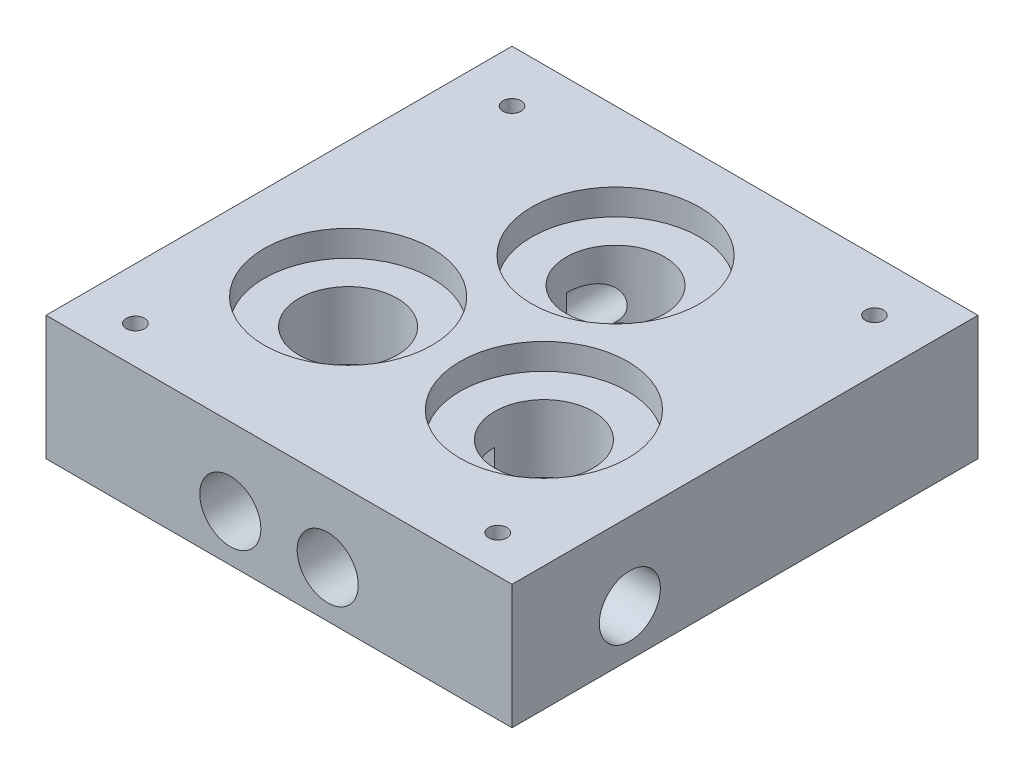
from build123d import *

# Parameters (mm, degrees)
SKETCH1_W                = 90.006
SKETCH1_H                = 90
SKETCH1_R                = 16.2
ALPHASENSE_HOUSING_DEPTH = 5
SKETCH2_W                = 90.006
SKETCH2_H                = 90
SKETCH2_R                = 9.5
CHAMBER_HOUSING_DEPTH    = 13
SKETCH3_W                = 90.006
SKETCH3_H                = 90
BASE_DEPTH               = 6
SKETCH5_R                = 5.9
DRILL_DEPTH              = 10
SKETCH6_R                = 5.9
DRILL2_DEPTH             = 10
SKETCH7_R                = 5.9
DRILL3_DEPTH             = 10
SKETCH8_R                = 5.9
INLETDRILL_DEPTH         = 10
SKETCH10_R               = 5.9
DRILL5_DEPTH             = 10
SKETCH11_R               = 5.9
OUTLEDRILL_DEPTH         = 10
SKETCH12_R               = 1.75
CLIPPINGTHREADS_DEPTH    = 10
SKETCH13_R               = 4
CUT_EXTRUDE1_DEPTH       = 35.003
SKETCH14_R               = 4
CUT_EXTRUDE2_DEPTH       = 16.098
SKETCH15_R               = 4
CUT_EXTRUDE3_DEPTH       = 22.255579
SKETCH16_R               = 4
CUT_EXTRUDE4_DEPTH       = 22.255579
SKETCH17_R               = 4
CUT_EXTRUDE5_DEPTH       = 16.098
SKETCH18_R               = 4
CUT_EXTRUDE6_DEPTH       = 15


with BuildPart() as part:
    # Sketch1 → Alphasense_housing (new body)
    with BuildSketch(Plane(origin=(0, 0, 0), x_dir=(1, 0, 0), z_dir=(0, 1, 0))):
        with Locations((0, 1.829613678)):
            Rectangle(SKETCH1_W, SKETCH1_H)
        with Locations((0, 21.829613678)):
            Circle(SKETCH1_R, mode=Mode.SUBTRACT)
        with Locations((-18.905, -10.914806839)):
            Circle(SKETCH1_R, mode=Mode.SUBTRACT)
        with Locations((18.905, -10.914806839)):
            Circle(SKETCH1_R, mode=Mode.SUBTRACT)
    extrude(amount=ALPHASENSE_HOUSING_DEPTH)

    # Sketch2 → Chamber_housing (add)
    with BuildSketch(Plane.XZ):
        with Locations((0, -1.829613678)):
            Rectangle(SKETCH2_W, SKETCH2_H)
        with Locations((-18.905, 10.914806839)):
            Circle(SKETCH2_R, mode=Mode.SUBTRACT)
        with Locations((18.905, 10.914806839)):
            Circle(SKETCH2_R, mode=Mode.SUBTRACT)
        with Locations((0, -21.829613678)):
            Circle(SKETCH2_R, mode=Mode.SUBTRACT)
    extrude(amount=CHAMBER_HOUSING_DEPTH)

    # Sketch3 → Base (add)
    with BuildSketch(Plane.XZ.offset(13)):
        with Locations((0, -1.829613678)):
            Rectangle(SKETCH3_W, SKETCH3_H)
    extrude(amount=BASE_DEPTH)

    # Sketch5 → Drill (cut)
    with BuildSketch(Plane.ZY.offset(45.003)):
        with Locations((20.414806839, -10)):
            Circle(SKETCH5_R)
    extrude(amount=-DRILL_DEPTH, mode=Mode.SUBTRACT)

    # Sketch6 → Drill2 (cut)
    with BuildSketch(Plane.XY.offset(43.170386322)):
        with Locations((-9.405, -10)):
            Circle(SKETCH6_R)
    extrude(amount=-DRILL2_DEPTH, mode=Mode.SUBTRACT)

    # Sketch7 → Drill3 (cut)
    with BuildSketch(Plane.XY.offset(43.170386322)):
        with Locations((9.405, -10)):
            Circle(SKETCH7_R)
    extrude(amount=-DRILL3_DEPTH, mode=Mode.SUBTRACT)

    # Sketch8 → InletDrill (cut)
    with BuildSketch(Plane(origin=(45.003, 0, 0), x_dir=(0, 0, -1), z_dir=(1, 0, 0))):
        with Locations((-20.414806839, -10)):
            Circle(SKETCH8_R)
    extrude(amount=-INLETDRILL_DEPTH, mode=Mode.SUBTRACT)

    # Sketch10 → Drill5 (cut)
    with BuildSketch(Plane.ZY.offset(45.003)):
        with Locations((-12.329613678, -10)):
            Circle(SKETCH10_R)
    extrude(amount=-DRILL5_DEPTH, mode=Mode.SUBTRACT)

    # Sketch11 → OutleDrill (cut)
    with BuildSketch(Plane(origin=(0, 0, -46.829613678), x_dir=(-1, 0, 0), z_dir=(0, 0, -1))):
        with Locations((9.5, -10)):
            Circle(SKETCH11_R)
    extrude(amount=-OUTLEDRILL_DEPTH, mode=Mode.SUBTRACT)

    # Sketch12 → ClippingThreads (cut)
    with BuildSketch(Plane(origin=(0, 5, 0), x_dir=(1, 0, 0), z_dir=(0, 1, 0))):
        with Locations((-35, 36.829613678)):
            Circle(SKETCH12_R)
        with Locations((35, 36.829613678)):
            Circle(SKETCH12_R)
        with Locations((-35, -35.914806839)):
            Circle(SKETCH12_R)
        with Locations((35, -35.914806839)):
            Circle(SKETCH12_R)
    extrude(amount=-CLIPPINGTHREADS_DEPTH, mode=Mode.SUBTRACT)

    # Sketch13 → Cut-Extrude1 (cut)
    with BuildSketch(Plane.ZY.offset(35.003)):
        with Locations((-12.329613678, -10)):
            Circle(SKETCH13_R)
    extrude(amount=-CUT_EXTRUDE1_DEPTH, mode=Mode.SUBTRACT)

    # Sketch14 → Cut-Extrude2 (cut)
    with BuildSketch(Plane.ZY.offset(35.003)):
        with Locations((20.414806839, -10)):
            Circle(SKETCH14_R)
    extrude(amount=-CUT_EXTRUDE2_DEPTH, mode=Mode.SUBTRACT)

    # Sketch15 → Cut-Extrude3 (cut)
    with BuildSketch(Plane.XY.offset(33.170386322)):
        with Locations((-9.405, -10)):
            Circle(SKETCH15_R)
    extrude(amount=-CUT_EXTRUDE3_DEPTH, mode=Mode.SUBTRACT)

    # Sketch16 → Cut-Extrude4 (cut)
    with BuildSketch(Plane.XY.offset(33.170386322)):
        with Locations((9.405, -10)):
            Circle(SKETCH16_R)
    extrude(amount=-CUT_EXTRUDE4_DEPTH, mode=Mode.SUBTRACT)

    # Sketch17 → Cut-Extrude5 (cut)
    with BuildSketch(Plane(origin=(35.003, 0, 0), x_dir=(0, 0, -1), z_dir=(1, 0, 0))):
        with Locations((-20.414806839, -10)):
            Circle(SKETCH17_R)
    extrude(amount=-CUT_EXTRUDE5_DEPTH, mode=Mode.SUBTRACT)

    # Sketch18 → Cut-Extrude6 (cut)
    with BuildSketch(Plane(origin=(0, 0, -36.829613678), x_dir=(-1, 0, 0), z_dir=(0, 0, -1))):
        with Locations((9.5, -10)):
            Circle(SKETCH18_R)
    extrude(amount=-CUT_EXTRUDE6_DEPTH, mode=Mode.SUBTRACT)


solid = part.part
